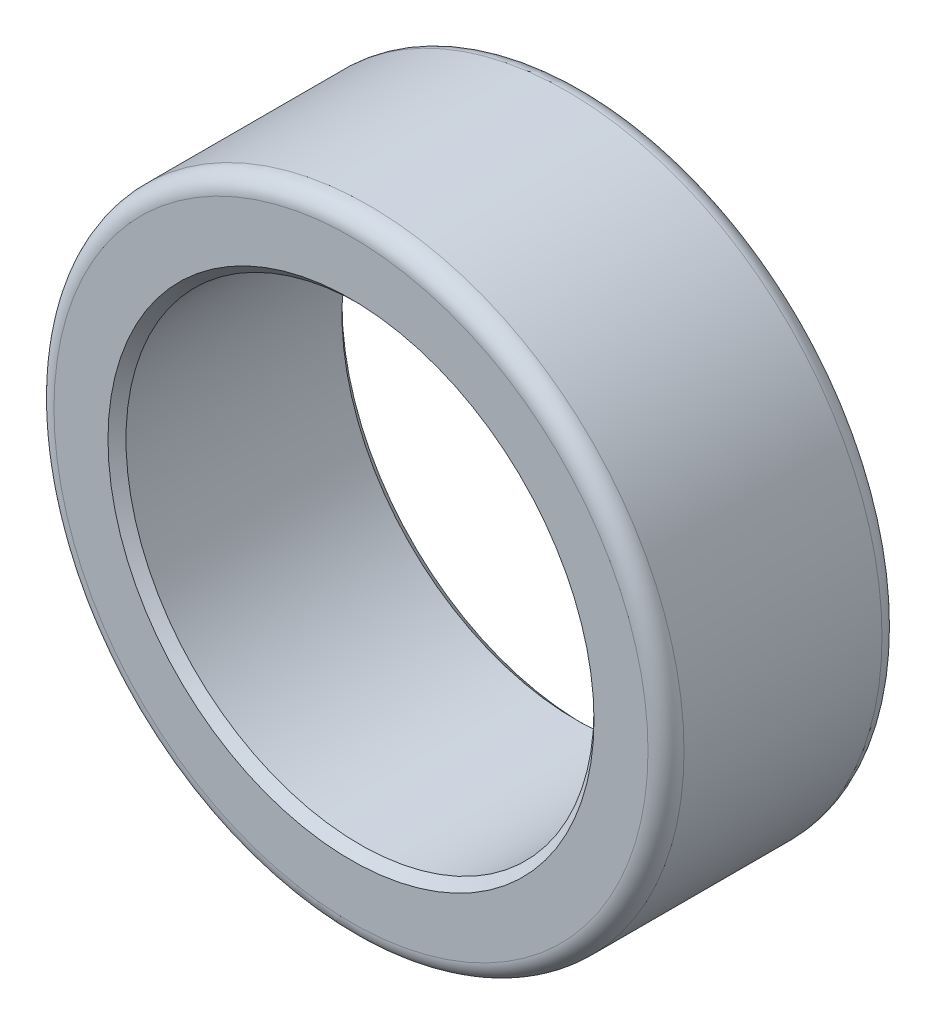
from build123d import *


with BuildPart() as part:
    # Croquis1 → Revolución1 (revolve)
    with BuildSketch(Plane(origin=(0, 0, 0), x_dir=(1, 0, 0), z_dir=(0, 1, 0))):
        with BuildLine():
            Line((26, -12), (26, 12))
            Line((26, 12), (27, 13))
            Line((27, 13), (33, 13))
            ThreePointArc((33, 13), (34.414213562, 12.414213562), (35, 11))
            Line((35, 11), (35, -11))
            ThreePointArc((35, -11), (34.414213562, -12.414213562), (33, -13))
            Line((33, -13), (27, -13))
            Line((27, -13), (26, -12))
        make_face()
    revolve(axis=Axis((0, 0, 0), (0, 0, -1)))


solid = part.part
